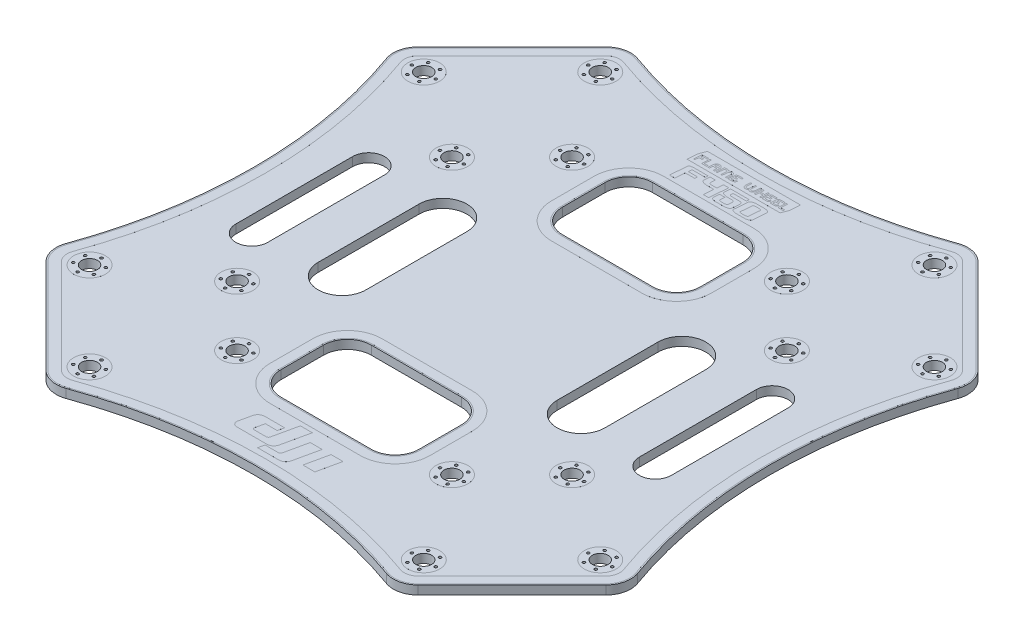
from build123d import *

# Parameters (mm, degrees)
BOSS_EXTRUDE1_DEPTH      = 0.825
BOSS_EXTRUDE1_DEPTH_BACK = 0.825
CUT_EXTRUDE1_DEPTH       = 1.65
SKETCH3_R                = 1.5
CUT_EXTRUDE2_DEPTH       = 1.65
SKETCH4_R                = 3
SKETCH4_R_2              = 1.5
SKETCH4_R_3              = 0.25
BOSS_EXTRUDE2_DEPTH      = 0.001
SKETCH5_R                = 0.25
CUT_EXTRUDE3_DEPTH       = 1.65
BOSS_EXTRUDE3_DEPTH      = 0.001


with BuildPart() as part:
    # Sketch1 → Boss-Extrude1 (new, two sides)
    with BuildSketch(Plane(origin=(0, 0, 0), x_dir=(1, 0, 0), z_dir=(0, 1, 0))) as boss_extrude1_sk:
        with BuildLine():
            Line((35.046361717, 52.705589829), (52.705589829, 35.046361717))
            ThreePointArc((52.705589829, 35.046361717), (53.961944938, 32.762265708), (53.8, 30.160478519))
            ThreePointArc((53.8, 30.160478519), (48.55, 0), (53.8, -30.160478519))
            ThreePointArc((53.8, -30.160478519), (53.961944938, -32.762265708), (52.705589829, -35.046361717))
            Line((52.705589829, -35.046361717), (35.046361717, -52.705589829))
            ThreePointArc((35.046361717, -52.705589829), (32.762265708, -53.961944938), (30.160478519, -53.8))
            ThreePointArc((30.160478519, -53.8), (0, -48.55), (-30.160478519, -53.8))
            ThreePointArc((-30.160478519, -53.8), (-32.762265708, -53.961944938), (-35.046361717, -52.705589829))
            Line((-35.046361717, -52.705589829), (-52.705589829, -35.046361717))
            ThreePointArc((-52.705589829, -35.046361717), (-53.961944938, -32.762265708), (-53.8, -30.160478519))
            ThreePointArc((-53.8, -30.160478519), (-48.55, 0), (-53.8, 30.160478519))
            ThreePointArc((-53.8, 30.160478519), (-53.961944938, 32.762265708), (-52.705589829, 35.046361717))
            Line((-52.705589829, 35.046361717), (-35.046361717, 52.705589829))
            ThreePointArc((-35.046361717, 52.705589829), (-32.762265708, 53.961944938), (-30.160478519, 53.8))
            ThreePointArc((-30.160478519, 53.8), (0, 48.55), (30.160478519, 53.8))
            ThreePointArc((30.160478519, 53.8), (32.762265708, 53.961944938), (35.046361717, 52.705589829))
        make_face()
    extrude(amount=BOSS_EXTRUDE1_DEPTH)
    extrude(boss_extrude1_sk.sketch, amount=-BOSS_EXTRUDE1_DEPTH_BACK)

    # Sketch2 → Cut-Extrude1 (cut)
    with BuildSketch(Plane(origin=(0, 0.825, 0), x_dir=(1, 0, 0), z_dir=(0, 1, 0))):
        with BuildLine():
            Line((13, 30.5), (13, 22.5))
            ThreePointArc((13, 22.5), (11.681980515, 19.318019485), (8.5, 18))
            Line((8.5, 18), (-8.5, 18))
            ThreePointArc((-8.5, 18), (-11.681980515, 19.318019485), (-13, 22.5))
            Line((-13, 22.5), (-13, 30.5))
            ThreePointArc((-13, 30.5), (-11.681980515, 33.681980515), (-8.5, 35))
            Line((-8.5, 35), (8.5, 35))
            ThreePointArc((8.5, 35), (11.681980515, 33.681980515), (13, 30.5))
        make_face()
        with BuildLine():
            Line((-13, -22.5), (-13, -30.5))
            ThreePointArc((-13, -30.5), (-11.681980515, -33.681980515), (-8.5, -35))
            Line((-8.5, -35), (8.5, -35))
            ThreePointArc((8.5, -35), (11.681980515, -33.681980515), (13, -30.5))
            Line((13, -30.5), (13, -22.5))
            ThreePointArc((13, -22.5), (11.681980515, -19.318019485), (8.5, -18))
            Line((8.5, -18), (-8.5, -18))
            ThreePointArc((-8.5, -18), (-11.681980515, -19.318019485), (-13, -22.5))
        make_face()
        with BuildLine():
            Line((-27, -9.5), (-27, 9.5))
            ThreePointArc((-27, 9.5), (-22.5, 14), (-18, 9.5))
            Line((-18, 9.5), (-18, -9.5))
            ThreePointArc((-18, -9.5), (-22.5, -14), (-27, -9.5))
        make_face()
        with BuildLine():
            Line((18, -9.5), (18, 9.5))
            ThreePointArc((18, 9.5), (22.5, 14), (27, 9.5))
            Line((27, 9.5), (27, -9.5))
            ThreePointArc((27, -9.5), (22.5, -14), (18, -9.5))
        make_face()
        with BuildLine():
            Line((-35, 11), (-35, -11))
            ThreePointArc((-35, -11), (-38, -14), (-41, -11))
            Line((-41, -11), (-41, 11))
            ThreePointArc((-41, 11), (-38, 14), (-35, 11))
        make_face()
        with BuildLine():
            Line((35, 11), (35, -11))
            ThreePointArc((35, -11), (38, -14), (41, -11))
            Line((41, -11), (41, 11))
            ThreePointArc((41, 11), (38, 14), (35, 11))
        make_face()
    extrude(amount=-CUT_EXTRUDE1_DEPTH, mode=Mode.SUBTRACT)

    # Sketch3 → Cut-Extrude2 (cut)
    with BuildSketch(Plane(origin=(0, 0.825, 0), x_dir=(1, 0, 0), z_dir=(0, 1, 0))):
        with Locations(Location((-48.083261121, -31.466251763, 0), (0, 0, 270))):
            Circle(SKETCH3_R)
        with Locations(Location((-31.466251763, -48.083261121, 0), (0, 0, 270))):
            Circle(SKETCH3_R)
        with Locations(Location((31.466251763, -48.083261121, 0), (0, 0, 270))):
            Circle(SKETCH3_R)
        with Locations(Location((48.083261121, -31.466251763, 0), (0, 0, 270))):
            Circle(SKETCH3_R)
        with Locations(Location((48.083261121, 31.466251763, 0), (0, 0, 270))):
            Circle(SKETCH3_R)
        with Locations(Location((31.466251763, 48.083261121, 0), (0, 0, 270))):
            Circle(SKETCH3_R)
        with Locations(Location((-31.466251763, 48.083261121, 0), (0, 0, 270))):
            Circle(SKETCH3_R)
        with Locations(Location((-48.083261121, 31.466251763, 0), (0, 0, 270))):
            Circle(SKETCH3_R)
        with Locations(Location((-31.540291459, -20.22658296, 0), (0, 0, 270))):
            Circle(SKETCH3_R)
        with Locations(Location((-20.22658296, -31.540291459, 0), (0, 0, 270))):
            Circle(SKETCH3_R)
        with Locations(Location((-31.540291459, 20.22658296, 0), (0, 0, 270))):
            Circle(SKETCH3_R)
        with Locations(Location((-20.22658296, 31.540291459, 0), (0, 0, 270))):
            Circle(SKETCH3_R)
        with Locations(Location((20.22658296, 31.540291459, 0), (0, 0, 270))):
            Circle(SKETCH3_R)
        with Locations(Location((31.540291459, 20.22658296, 0), (0, 0, 270))):
            Circle(SKETCH3_R)
        with Locations(Location((31.540291459, -20.22658296, 0), (0, 0, 270))):
            Circle(SKETCH3_R)
        with Locations(Location((20.22658296, -31.540291459, 0), (0, 0, 270))):
            Circle(SKETCH3_R)
    extrude(amount=-CUT_EXTRUDE2_DEPTH, mode=Mode.SUBTRACT)

    # Sketch4 → Boss-Extrude2 (add)
    with BuildSketch(Plane(origin=(0, 0.825, 0), x_dir=(1, 0, 0), z_dir=(0, 1, 0))):
        with BuildLine():
            Line((34.869585021, -52.528813133), (52.528813133, -34.869585021))
            ThreePointArc((52.528813133, -34.869585021), (53.71799007, -32.707621199), (53.564704439, -30.244953362))
            ThreePointArc((53.564704439, -30.244953362), (48.3, 0), (53.564704439, 30.244953362))
            ThreePointArc((53.564704439, 30.244953362), (53.71799007, 32.707621199), (52.528813133, 34.869585021))
            Line((52.528813133, 34.869585021), (34.869585021, 52.528813133))
            ThreePointArc((34.869585021, 52.528813133), (32.707621199, 53.71799007), (30.244953362, 53.564704439))
            ThreePointArc((30.244953362, 53.564704439), (0, 48.3), (-30.244953362, 53.564704439))
            ThreePointArc((-30.244953362, 53.564704439), (-32.707621199, 53.71799007), (-34.869585021, 52.528813133))
            Line((-34.869585021, 52.528813133), (-52.528813133, 34.869585021))
            ThreePointArc((-52.528813133, 34.869585021), (-53.71799007, 32.707621199), (-53.564704439, 30.244953362))
            ThreePointArc((-53.564704439, 30.244953362), (-48.3, 0), (-53.564704439, -30.244953362))
            ThreePointArc((-53.564704439, -30.244953362), (-53.71799007, -32.707621199), (-52.528813133, -34.869585021))
            Line((-52.528813133, -34.869585021), (-34.869585021, -52.528813133))
            ThreePointArc((-34.869585021, -52.528813133), (-32.707621199, -53.71799007), (-30.244953362, -53.564704439))
            ThreePointArc((-30.244953362, -53.564704439), (0, -48.3), (30.244953362, -53.564704439))
            ThreePointArc((30.244953362, -53.564704439), (32.707621199, -53.71799007), (34.869585021, -52.528813133))
        make_face()
        with BuildLine():
            Line((-51.256020927, 33.596792815), (-33.596792815, 51.256020927))
            ThreePointArc((-33.596792815, 51.256020927), (-32.314180733, 51.961515021), (-30.853172233, 51.870576403))
            ThreePointArc((-30.853172233, 51.870576403), (0, 46.5), (30.853172233, 51.870576403))
            ThreePointArc((30.853172233, 51.870576403), (32.314180733, 51.961515021), (33.596792815, 51.256020927))
            Line((33.596792815, 51.256020927), (51.256020927, 33.596792815))
            ThreePointArc((51.256020927, 33.596792815), (51.961515021, 32.314180733), (51.870576403, 30.853172233))
            ThreePointArc((51.870576403, 30.853172233), (46.5, 0), (51.870576403, -30.853172233))
            ThreePointArc((51.870576403, -30.853172233), (51.961515021, -32.314180733), (51.256020927, -33.596792815))
            Line((51.256020927, -33.596792815), (33.596792815, -51.256020927))
            ThreePointArc((33.596792815, -51.256020927), (32.314180733, -51.961515021), (30.853172233, -51.870576403))
            ThreePointArc((30.853172233, -51.870576403), (0, -46.5), (-30.853172233, -51.870576403))
            ThreePointArc((-30.853172233, -51.870576403), (-32.314180733, -51.961515021), (-33.596792815, -51.256020927))
            Line((-33.596792815, -51.256020927), (-51.256020927, -33.596792815))
            ThreePointArc((-51.256020927, -33.596792815), (-51.961515021, -32.314180733), (-51.870576403, -30.853172233))
            ThreePointArc((-51.870576403, -30.853172233), (-46.5, 0), (-51.870576403, 30.853172233))
            ThreePointArc((-51.870576403, 30.853172233), (-51.961515021, 32.314180733), (-51.256020927, 33.596792815))
        make_face(mode=Mode.SUBTRACT)
        with BuildLine():
            Line((15.05, 30.5), (15.05, 22.5))
            ThreePointArc((15.05, 22.5), (13.131549417, 17.868450583), (8.5, 15.95))
            Line((8.5, 15.95), (-8.5, 15.95))
            ThreePointArc((-8.5, 15.95), (-13.131549417, 17.868450583), (-15.05, 22.5))
            Line((-15.05, 22.5), (-15.05, 30.5))
            ThreePointArc((-15.05, 30.5), (-13.131549417, 35.131549417), (-8.5, 37.05))
            Line((-8.5, 37.05), (8.5, 37.05))
            ThreePointArc((8.5, 37.05), (13.131549417, 35.131549417), (15.05, 30.5))
        make_face()
        with BuildLine():
            Line((-8.5, 17.75), (8.5, 17.75))
            ThreePointArc((8.5, 17.75), (11.858757211, 19.141242789), (13.25, 22.5))
            Line((13.25, 22.5), (13.25, 30.5))
            ThreePointArc((13.25, 30.5), (11.858757211, 33.858757211), (8.5, 35.25))
            Line((8.5, 35.25), (-8.5, 35.25))
            ThreePointArc((-8.5, 35.25), (-11.858757211, 33.858757211), (-13.25, 30.5))
            Line((-13.25, 30.5), (-13.25, 22.5))
            ThreePointArc((-13.25, 22.5), (-11.858757211, 19.141242789), (-8.5, 17.75))
        make_face(mode=Mode.SUBTRACT)
        with BuildLine():
            Line((15.05, -30.5), (15.05, -22.5))
            ThreePointArc((15.05, -22.5), (13.131549417, -17.868450583), (8.5, -15.95))
            Line((8.5, -15.95), (-8.5, -15.95))
            ThreePointArc((-8.5, -15.95), (-13.131549417, -17.868450583), (-15.05, -22.5))
            Line((-15.05, -22.5), (-15.05, -30.5))
            ThreePointArc((-15.05, -30.5), (-13.131549417, -35.131549417), (-8.5, -37.05))
            Line((-8.5, -37.05), (8.5, -37.05))
            ThreePointArc((8.5, -37.05), (13.131549417, -35.131549417), (15.05, -30.5))
        make_face()
        with BuildLine():
            Line((13.25, -30.5), (13.25, -22.5))
            ThreePointArc((13.25, -22.5), (11.858757211, -19.141242789), (8.5, -17.75))
            Line((8.5, -17.75), (-8.5, -17.75))
            ThreePointArc((-8.5, -17.75), (-11.858757211, -19.141242789), (-13.25, -22.5))
            Line((-13.25, -22.5), (-13.25, -30.5))
            ThreePointArc((-13.25, -30.5), (-11.858757211, -33.858757211), (-8.5, -35.25))
            Line((-8.5, -35.25), (8.5, -35.25))
            ThreePointArc((8.5, -35.25), (11.858757211, -33.858757211), (13.25, -30.5))
        make_face(mode=Mode.SUBTRACT)
        with Locations(Location((31.466251763, -48.083261121, 0), (0, 0, 270))):
            Circle(SKETCH4_R)
        with Locations(Location((31.466251763, -48.083261121, 0), (0, 0, 270))):
            Circle(SKETCH4_R_2, mode=Mode.SUBTRACT)
        with Locations(Location((30.341251763, -50.031818279, 0), (0, 0, 270))):
            Circle(SKETCH4_R_3, mode=Mode.SUBTRACT)
        with Locations(Location((29.216251763, -48.083261121, 0), (0, 0, 270))):
            Circle(SKETCH4_R_3, mode=Mode.SUBTRACT)
        with Locations(Location((30.341251763, -46.134703962, 0), (0, 0, 270))):
            Circle(SKETCH4_R_3, mode=Mode.SUBTRACT)
        with Locations(Location((32.591251763, -46.134703962, 0), (0, 0, 270))):
            Circle(SKETCH4_R_3, mode=Mode.SUBTRACT)
        with Locations(Location((33.716251763, -48.083261121, 0), (0, 0, 270))):
            Circle(SKETCH4_R_3, mode=Mode.SUBTRACT)
        with Locations(Location((32.591251763, -50.031818279, 0), (0, 0, 270))):
            Circle(SKETCH4_R_3, mode=Mode.SUBTRACT)
        with Locations(Location((48.083261121, -31.466251763, 0), (0, 0, 270))):
            Circle(SKETCH4_R)
        with Locations(Location((48.083261121, -31.466251763, 0), (0, 0, 270))):
            Circle(SKETCH4_R_2, mode=Mode.SUBTRACT)
        with Locations(Location((46.958261121, -33.414808921, 0), (0, 0, 270))):
            Circle(SKETCH4_R_3, mode=Mode.SUBTRACT)
        with Locations(Location((45.833261121, -31.466251763, 0), (0, 0, 270))):
            Circle(SKETCH4_R_3, mode=Mode.SUBTRACT)
        with Locations(Location((46.958261121, -29.517694604, 0), (0, 0, 270))):
            Circle(SKETCH4_R_3, mode=Mode.SUBTRACT)
        with Locations(Location((49.208261121, -29.517694604, 0), (0, 0, 270))):
            Circle(SKETCH4_R_3, mode=Mode.SUBTRACT)
        with Locations(Location((50.333261121, -31.466251763, 0), (0, 0, 270))):
            Circle(SKETCH4_R_3, mode=Mode.SUBTRACT)
        with Locations(Location((49.208261121, -33.414808921, 0), (0, 0, 270))):
            Circle(SKETCH4_R_3, mode=Mode.SUBTRACT)
        with Locations(Location((31.540291459, -20.22658296, 0), (0, 0, 270))):
            Circle(SKETCH4_R)
        with Locations(Location((31.540291459, -20.22658296, 0), (0, 0, 270))):
            Circle(SKETCH4_R_2, mode=Mode.SUBTRACT)
        with Locations(Location((30.415291459, -22.175140119, 0), (0, 0, 270))):
            Circle(SKETCH4_R_3, mode=Mode.SUBTRACT)
        with Locations(Location((29.290291459, -20.22658296, 0), (0, 0, 270))):
            Circle(SKETCH4_R_3, mode=Mode.SUBTRACT)
        with Locations(Location((30.415291459, -18.278025802, 0), (0, 0, 270))):
            Circle(SKETCH4_R_3, mode=Mode.SUBTRACT)
        with Locations(Location((32.665291459, -18.278025802, 0), (0, 0, 270))):
            Circle(SKETCH4_R_3, mode=Mode.SUBTRACT)
        with Locations(Location((33.790291459, -20.22658296, 0), (0, 0, 270))):
            Circle(SKETCH4_R_3, mode=Mode.SUBTRACT)
        with Locations(Location((32.665291459, -22.175140119, 0), (0, 0, 270))):
            Circle(SKETCH4_R_3, mode=Mode.SUBTRACT)
        with Locations(Location((20.22658296, -31.540291459, 0), (0, 0, 270))):
            Circle(SKETCH4_R)
        with Locations(Location((20.22658296, -31.540291459, 0), (0, 0, 270))):
            Circle(SKETCH4_R_2, mode=Mode.SUBTRACT)
        with Locations(Location((19.10158296, -33.488848618, 0), (0, 0, 270))):
            Circle(SKETCH4_R_3, mode=Mode.SUBTRACT)
        with Locations(Location((21.35158296, -33.488848618, 0), (0, 0, 270))):
            Circle(SKETCH4_R_3, mode=Mode.SUBTRACT)
        with Locations(Location((22.47658296, -31.540291459, 0), (0, 0, 270))):
            Circle(SKETCH4_R_3, mode=Mode.SUBTRACT)
        with Locations(Location((21.35158296, -29.591734301, 0), (0, 0, 270))):
            Circle(SKETCH4_R_3, mode=Mode.SUBTRACT)
        with Locations(Location((19.10158296, -29.591734301, 0), (0, 0, 270))):
            Circle(SKETCH4_R_3, mode=Mode.SUBTRACT)
        with Locations(Location((17.97658296, -31.540291459, 0), (0, 0, 270))):
            Circle(SKETCH4_R_3, mode=Mode.SUBTRACT)
        with Locations(Location((31.540291459, 20.22658296, 0), (0, 0, 270))):
            Circle(SKETCH4_R)
        with Locations(Location((31.540291459, 20.22658296, 0), (0, 0, 270))):
            Circle(SKETCH4_R_2, mode=Mode.SUBTRACT)
        with Locations(Location((29.591734301, 21.35158296, 0), (0, 0, 270))):
            Circle(SKETCH4_R_3, mode=Mode.SUBTRACT)
        with Locations(Location((29.591734301, 19.10158296, 0), (0, 0, 270))):
            Circle(SKETCH4_R_3, mode=Mode.SUBTRACT)
        with Locations(Location((31.540291459, 17.97658296, 0), (0, 0, 270))):
            Circle(SKETCH4_R_3, mode=Mode.SUBTRACT)
        with Locations(Location((33.488848618, 19.10158296, 0), (0, 0, 270))):
            Circle(SKETCH4_R_3, mode=Mode.SUBTRACT)
        with Locations(Location((33.488848618, 21.35158296, 0), (0, 0, 270))):
            Circle(SKETCH4_R_3, mode=Mode.SUBTRACT)
        with Locations(Location((31.540291459, 22.47658296, 0), (0, 0, 270))):
            Circle(SKETCH4_R_3, mode=Mode.SUBTRACT)
        with Locations(Location((48.083261121, 31.466251763, 0), (0, 0, 270))):
            Circle(SKETCH4_R)
        with Locations(Location((48.083261121, 31.466251763, 0), (0, 0, 270))):
            Circle(SKETCH4_R_2, mode=Mode.SUBTRACT)
        with Locations(Location((48.083261121, 29.216251763, 0), (0, 0, 270))):
            Circle(SKETCH4_R_3, mode=Mode.SUBTRACT)
        with Locations(Location((46.134703962, 30.341251763, 0), (0, 0, 270))):
            Circle(SKETCH4_R_3, mode=Mode.SUBTRACT)
        with Locations(Location((50.031818279, 30.341251763, 0), (0, 0, 270))):
            Circle(SKETCH4_R_3, mode=Mode.SUBTRACT)
        with Locations(Location((50.031818279, 32.591251763, 0), (0, 0, 270))):
            Circle(SKETCH4_R_3, mode=Mode.SUBTRACT)
        with Locations(Location((48.083261121, 33.716251763, 0), (0, 0, 270))):
            Circle(SKETCH4_R_3, mode=Mode.SUBTRACT)
        with Locations(Location((46.134703962, 32.591251763, 0), (0, 0, 270))):
            Circle(SKETCH4_R_3, mode=Mode.SUBTRACT)
        with Locations(Location((31.466251763, 48.083261121, 0), (0, 0, 270))):
            Circle(SKETCH4_R)
        with Locations(Location((31.466251763, 48.083261121, 0), (0, 0, 270))):
            Circle(SKETCH4_R_2, mode=Mode.SUBTRACT)
        with Locations(Location((31.466251763, 45.833261121, 0), (0, 0, 270))):
            Circle(SKETCH4_R_3, mode=Mode.SUBTRACT)
        with Locations(Location((29.517694604, 46.958261121, 0), (0, 0, 270))):
            Circle(SKETCH4_R_3, mode=Mode.SUBTRACT)
        with Locations(Location((29.517694604, 49.208261121, 0), (0, 0, 270))):
            Circle(SKETCH4_R_3, mode=Mode.SUBTRACT)
        with Locations(Location((31.466251763, 50.333261121, 0), (0, 0, 270))):
            Circle(SKETCH4_R_3, mode=Mode.SUBTRACT)
        with Locations(Location((33.414808921, 49.208261121, 0), (0, 0, 270))):
            Circle(SKETCH4_R_3, mode=Mode.SUBTRACT)
        with Locations(Location((33.414808921, 46.958261121, 0), (0, 0, 270))):
            Circle(SKETCH4_R_3, mode=Mode.SUBTRACT)
        with Locations(Location((20.22658296, 31.540291459, 0), (0, 0, 270))):
            Circle(SKETCH4_R)
        with Locations(Location((20.22658296, 31.540291459, 0), (0, 0, 270))):
            Circle(SKETCH4_R_2, mode=Mode.SUBTRACT)
        with Locations(Location((20.22658296, 29.290291459, 0), (0, 0, 270))):
            Circle(SKETCH4_R_3, mode=Mode.SUBTRACT)
        with Locations(Location((22.175140119, 30.415291459, 0), (0, 0, 270))):
            Circle(SKETCH4_R_3, mode=Mode.SUBTRACT)
        with Locations(Location((22.175140119, 32.665291459, 0), (0, 0, 270))):
            Circle(SKETCH4_R_3, mode=Mode.SUBTRACT)
        with Locations(Location((18.278025802, 30.415291459, 0), (0, 0, 270))):
            Circle(SKETCH4_R_3, mode=Mode.SUBTRACT)
        with Locations(Location((18.278025802, 32.665291459, 0), (0, 0, 270))):
            Circle(SKETCH4_R_3, mode=Mode.SUBTRACT)
        with Locations(Location((20.22658296, 33.790291459, 0), (0, 0, 270))):
            Circle(SKETCH4_R_3, mode=Mode.SUBTRACT)
        with Locations(Location((-31.466251763, 48.083261121, 0), (0, 0, 270))):
            Circle(SKETCH4_R)
        with Locations(Location((-31.466251763, 48.083261121, 0), (0, 0, 270))):
            Circle(SKETCH4_R_2, mode=Mode.SUBTRACT)
        with Locations(Location((-32.591251763, 46.134703962, 0), (0, 0, 270))):
            Circle(SKETCH4_R_3, mode=Mode.SUBTRACT)
        with Locations(Location((-33.716251763, 48.083261121, 0), (0, 0, 270))):
            Circle(SKETCH4_R_3, mode=Mode.SUBTRACT)
        with Locations(Location((-32.591251763, 50.031818279, 0), (0, 0, 270))):
            Circle(SKETCH4_R_3, mode=Mode.SUBTRACT)
        with Locations(Location((-30.341251763, 50.031818279, 0), (0, 0, 270))):
            Circle(SKETCH4_R_3, mode=Mode.SUBTRACT)
        with Locations(Location((-29.216251763, 48.083261121, 0), (0, 0, 270))):
            Circle(SKETCH4_R_3, mode=Mode.SUBTRACT)
        with Locations(Location((-30.341251763, 46.134703962, 0), (0, 0, 270))):
            Circle(SKETCH4_R_3, mode=Mode.SUBTRACT)
        with Locations(Location((-20.22658296, 31.540291459, 0), (0, 0, 270))):
            Circle(SKETCH4_R)
        with Locations(Location((-20.22658296, 31.540291459, 0), (0, 0, 270))):
            Circle(SKETCH4_R_2, mode=Mode.SUBTRACT)
        with Locations(Location((-19.10158296, 29.591734301, 0), (0, 0, 270))):
            Circle(SKETCH4_R_3, mode=Mode.SUBTRACT)
        with Locations(Location((-21.35158296, 29.591734301, 0), (0, 0, 270))):
            Circle(SKETCH4_R_3, mode=Mode.SUBTRACT)
        with Locations(Location((-22.47658296, 31.540291459, 0), (0, 0, 270))):
            Circle(SKETCH4_R_3, mode=Mode.SUBTRACT)
        with Locations(Location((-21.35158296, 33.488848618, 0), (0, 0, 270))):
            Circle(SKETCH4_R_3, mode=Mode.SUBTRACT)
        with Locations(Location((-19.10158296, 33.488848618, 0), (0, 0, 270))):
            Circle(SKETCH4_R_3, mode=Mode.SUBTRACT)
        with Locations(Location((-17.97658296, 31.540291459, 0), (0, 0, 270))):
            Circle(SKETCH4_R_3, mode=Mode.SUBTRACT)
        with Locations(Location((-31.540291459, 20.22658296, 0), (0, 0, 270))):
            Circle(SKETCH4_R)
        with Locations(Location((-31.540291459, 20.22658296, 0), (0, 0, 270))):
            Circle(SKETCH4_R_2, mode=Mode.SUBTRACT)
        with Locations(Location((-32.665291459, 18.278025802, 0), (0, 0, 270))):
            Circle(SKETCH4_R_3, mode=Mode.SUBTRACT)
        with Locations(Location((-33.790291459, 20.22658296, 0), (0, 0, 270))):
            Circle(SKETCH4_R_3, mode=Mode.SUBTRACT)
        with Locations(Location((-32.665291459, 22.175140119, 0), (0, 0, 270))):
            Circle(SKETCH4_R_3, mode=Mode.SUBTRACT)
        with Locations(Location((-30.415291459, 22.175140119, 0), (0, 0, 270))):
            Circle(SKETCH4_R_3, mode=Mode.SUBTRACT)
        with Locations(Location((-29.290291459, 20.22658296, 0), (0, 0, 270))):
            Circle(SKETCH4_R_3, mode=Mode.SUBTRACT)
        with Locations(Location((-30.415291459, 18.278025802, 0), (0, 0, 270))):
            Circle(SKETCH4_R_3, mode=Mode.SUBTRACT)
        with Locations(Location((-48.083261121, 31.466251763, 0), (0, 0, 270))):
            Circle(SKETCH4_R)
        with Locations(Location((-48.083261121, 31.466251763, 0), (0, 0, 270))):
            Circle(SKETCH4_R_2, mode=Mode.SUBTRACT)
        with Locations(Location((-46.958261121, 29.517694604, 0), (0, 0, 270))):
            Circle(SKETCH4_R_3, mode=Mode.SUBTRACT)
        with Locations(Location((-45.833261121, 31.466251763, 0), (0, 0, 270))):
            Circle(SKETCH4_R_3, mode=Mode.SUBTRACT)
        with Locations(Location((-46.958261121, 33.414808921, 0), (0, 0, 270))):
            Circle(SKETCH4_R_3, mode=Mode.SUBTRACT)
        with Locations(Location((-49.208261121, 33.414808921, 0), (0, 0, 270))):
            Circle(SKETCH4_R_3, mode=Mode.SUBTRACT)
        with Locations(Location((-50.333261121, 31.466251763, 0), (0, 0, 270))):
            Circle(SKETCH4_R_3, mode=Mode.SUBTRACT)
        with Locations(Location((-49.208261121, 29.517694604, 0), (0, 0, 270))):
            Circle(SKETCH4_R_3, mode=Mode.SUBTRACT)
        with Locations(Location((-20.22658296, -31.540291459, 0), (0, 0, 270))):
            Circle(SKETCH4_R)
        with Locations(Location((-20.22658296, -31.540291459, 0), (0, 0, 270))):
            Circle(SKETCH4_R_2, mode=Mode.SUBTRACT)
        with Locations(Location((-20.22658296, -33.790291459, 0), (0, 0, 270))):
            Circle(SKETCH4_R_3, mode=Mode.SUBTRACT)
        with Locations(Location((-18.278025802, -32.665291459, 0), (0, 0, 270))):
            Circle(SKETCH4_R_3, mode=Mode.SUBTRACT)
        with Locations(Location((-18.278025802, -30.415291459, 0), (0, 0, 270))):
            Circle(SKETCH4_R_3, mode=Mode.SUBTRACT)
        with Locations(Location((-20.22658296, -29.290291459, 0), (0, 0, 270))):
            Circle(SKETCH4_R_3, mode=Mode.SUBTRACT)
        with Locations(Location((-22.175140119, -30.415291459, 0), (0, 0, 270))):
            Circle(SKETCH4_R_3, mode=Mode.SUBTRACT)
        with Locations(Location((-22.175140119, -32.665291459, 0), (0, 0, 270))):
            Circle(SKETCH4_R_3, mode=Mode.SUBTRACT)
        with Locations(Location((-31.540291459, -20.22658296, 0), (0, 0, 270))):
            Circle(SKETCH4_R)
        with Locations(Location((-31.540291459, -20.22658296, 0), (0, 0, 270))):
            Circle(SKETCH4_R_2, mode=Mode.SUBTRACT)
        with Locations(Location((-31.540291459, -22.47658296, 0), (0, 0, 270))):
            Circle(SKETCH4_R_3, mode=Mode.SUBTRACT)
        with Locations(Location((-29.591734301, -21.35158296, 0), (0, 0, 270))):
            Circle(SKETCH4_R_3, mode=Mode.SUBTRACT)
        with Locations(Location((-29.591734301, -19.10158296, 0), (0, 0, 270))):
            Circle(SKETCH4_R_3, mode=Mode.SUBTRACT)
        with Locations(Location((-31.540291459, -17.97658296, 0), (0, 0, 270))):
            Circle(SKETCH4_R_3, mode=Mode.SUBTRACT)
        with Locations(Location((-33.488848618, -19.10158296, 0), (0, 0, 270))):
            Circle(SKETCH4_R_3, mode=Mode.SUBTRACT)
        with Locations(Location((-33.488848618, -21.35158296, 0), (0, 0, 270))):
            Circle(SKETCH4_R_3, mode=Mode.SUBTRACT)
        with Locations(Location((-48.083261121, -31.466251763, 0), (0, 0, 270))):
            Circle(SKETCH4_R)
        with Locations(Location((-48.083261121, -31.466251763, 0), (0, 0, 270))):
            Circle(SKETCH4_R_2, mode=Mode.SUBTRACT)
        with Locations(Location((-48.083261121, -33.716251763, 0), (0, 0, 270))):
            Circle(SKETCH4_R_3, mode=Mode.SUBTRACT)
        with Locations(Location((-46.134703962, -32.591251763, 0), (0, 0, 270))):
            Circle(SKETCH4_R_3, mode=Mode.SUBTRACT)
        with Locations(Location((-46.134703962, -30.341251763, 0), (0, 0, 270))):
            Circle(SKETCH4_R_3, mode=Mode.SUBTRACT)
        with Locations(Location((-48.083261121, -29.216251763, 0), (0, 0, 270))):
            Circle(SKETCH4_R_3, mode=Mode.SUBTRACT)
        with Locations(Location((-50.031818279, -30.341251763, 0), (0, 0, 270))):
            Circle(SKETCH4_R_3, mode=Mode.SUBTRACT)
        with Locations(Location((-50.031818279, -32.591251763, 0), (0, 0, 270))):
            Circle(SKETCH4_R_3, mode=Mode.SUBTRACT)
        with Locations(Location((-31.466251763, -48.083261121, 0), (0, 0, 270))):
            Circle(SKETCH4_R)
        with Locations(Location((-31.466251763, -48.083261121, 0), (0, 0, 270))):
            Circle(SKETCH4_R_2, mode=Mode.SUBTRACT)
        with Locations(Location((-31.466251763, -50.333261121, 0), (0, 0, 270))):
            Circle(SKETCH4_R_3, mode=Mode.SUBTRACT)
        with Locations(Location((-29.517694604, -49.208261121, 0), (0, 0, 270))):
            Circle(SKETCH4_R_3, mode=Mode.SUBTRACT)
        with Locations(Location((-29.517694604, -46.958261121, 0), (0, 0, 270))):
            Circle(SKETCH4_R_3, mode=Mode.SUBTRACT)
        with Locations(Location((-31.466251763, -45.833261121, 0), (0, 0, 270))):
            Circle(SKETCH4_R_3, mode=Mode.SUBTRACT)
        with Locations(Location((-33.414808921, -46.958261121, 0), (0, 0, 270))):
            Circle(SKETCH4_R_3, mode=Mode.SUBTRACT)
        with Locations(Location((-33.414808921, -49.208261121, 0), (0, 0, 270))):
            Circle(SKETCH4_R_3, mode=Mode.SUBTRACT)
    boss_extrude2 = extrude(amount=BOSS_EXTRUDE2_DEPTH)

    # Mirror2: Boss-Extrude2 across plane
    add(boss_extrude2.mirror(Plane.ZX))

    # Sketch5 → Cut-Extrude3 (cut)
    with BuildSketch(Plane(origin=(0, 0.825, 0), x_dir=(1, 0, 0), z_dir=(0, 1, 0))):
        with Locations(Location((-31.466251763, -45.833261121, 0), (0, 0, 270))):
            Circle(SKETCH5_R)
        with Locations(Location((-29.517694604, -46.958261121, 0), (0, 0, 270))):
            Circle(SKETCH5_R)
        with Locations(Location((-29.517694604, -49.208261121, 0), (0, 0, 270))):
            Circle(SKETCH5_R)
        with Locations(Location((-31.466251763, -50.333261121, 0), (0, 0, 270))):
            Circle(SKETCH5_R)
        with Locations(Location((-33.414808921, -49.208261121, 0), (0, 0, 270))):
            Circle(SKETCH5_R)
        with Locations(Location((-33.414808921, -46.958261121, 0), (0, 0, 270))):
            Circle(SKETCH5_R)
        with Locations(Location((-48.083261121, -33.716251763, 0), (0, 0, 270))):
            Circle(SKETCH5_R)
        with Locations(Location((-50.031818279, -32.591251763, 0), (0, 0, 270))):
            Circle(SKETCH5_R)
        with Locations(Location((-50.031818279, -30.341251763, 0), (0, 0, 270))):
            Circle(SKETCH5_R)
        with Locations(Location((-48.083261121, -29.216251763, 0), (0, 0, 270))):
            Circle(SKETCH5_R)
        with Locations(Location((-46.134703962, -30.341251763, 0), (0, 0, 270))):
            Circle(SKETCH5_R)
        with Locations(Location((-46.134703962, -32.591251763, 0), (0, 0, 270))):
            Circle(SKETCH5_R)
        with Locations(Location((-33.488848618, -21.35158296, 0), (0, 0, 270))):
            Circle(SKETCH5_R)
        with Locations(Location((-33.488848618, -19.10158296, 0), (0, 0, 270))):
            Circle(SKETCH5_R)
        with Locations(Location((-31.540291459, -17.97658296, 0), (0, 0, 270))):
            Circle(SKETCH5_R)
        with Locations(Location((-29.591734301, -19.10158296, 0), (0, 0, 270))):
            Circle(SKETCH5_R)
        with Locations(Location((-29.591734301, -21.35158296, 0), (0, 0, 270))):
            Circle(SKETCH5_R)
        with Locations(Location((-31.540291459, -22.47658296, 0), (0, 0, 270))):
            Circle(SKETCH5_R)
        with Locations(Location((-22.175140119, -30.415291459, 0), (0, 0, 270))):
            Circle(SKETCH5_R)
        with Locations(Location((-22.175140119, -32.665291459, 0), (0, 0, 270))):
            Circle(SKETCH5_R)
        with Locations(Location((-20.22658296, -33.790291459, 0), (0, 0, 270))):
            Circle(SKETCH5_R)
        with Locations(Location((-18.278025802, -32.665291459, 0), (0, 0, 270))):
            Circle(SKETCH5_R)
        with Locations(Location((-18.278025802, -30.415291459, 0), (0, 0, 270))):
            Circle(SKETCH5_R)
        with Locations(Location((-20.22658296, -29.290291459, 0), (0, 0, 270))):
            Circle(SKETCH5_R)
        with Locations(Location((19.10158296, -33.488848618, 0), (0, 0, 270))):
            Circle(SKETCH5_R)
        with Locations(Location((17.97658296, -31.540291459, 0), (0, 0, 270))):
            Circle(SKETCH5_R)
        with Locations(Location((19.10158296, -29.591734301, 0), (0, 0, 270))):
            Circle(SKETCH5_R)
        with Locations(Location((21.35158296, -29.591734301, 0), (0, 0, 270))):
            Circle(SKETCH5_R)
        with Locations(Location((22.47658296, -31.540291459, 0), (0, 0, 270))):
            Circle(SKETCH5_R)
        with Locations(Location((21.35158296, -33.488848618, 0), (0, 0, 270))):
            Circle(SKETCH5_R)
        with Locations(Location((29.290291459, -20.22658296, 0), (0, 0, 270))):
            Circle(SKETCH5_R)
        with Locations(Location((30.415291459, -18.278025802, 0), (0, 0, 270))):
            Circle(SKETCH5_R)
        with Locations(Location((32.665291459, -18.278025802, 0), (0, 0, 270))):
            Circle(SKETCH5_R)
        with Locations(Location((30.415291459, -22.175140119, 0), (0, 0, 270))):
            Circle(SKETCH5_R)
        with Locations(Location((32.665291459, -22.175140119, 0), (0, 0, 270))):
            Circle(SKETCH5_R)
        with Locations(Location((33.790291459, -20.22658296, 0), (0, 0, 270))):
            Circle(SKETCH5_R)
        with Locations(Location((46.958261121, -29.517694604, 0), (0, 0, 270))):
            Circle(SKETCH5_R)
        with Locations(Location((49.208261121, -29.517694604, 0), (0, 0, 270))):
            Circle(SKETCH5_R)
        with Locations(Location((45.833261121, -31.466251763, 0), (0, 0, 270))):
            Circle(SKETCH5_R)
        with Locations(Location((46.958261121, -33.414808921, 0), (0, 0, 270))):
            Circle(SKETCH5_R)
        with Locations(Location((49.208261121, -33.414808921, 0), (0, 0, 270))):
            Circle(SKETCH5_R)
        with Locations(Location((50.333261121, -31.466251763, 0), (0, 0, 270))):
            Circle(SKETCH5_R)
        with Locations(Location((30.341251763, -46.134703962, 0), (0, 0, 270))):
            Circle(SKETCH5_R)
        with Locations(Location((32.591251763, -46.134703962, 0), (0, 0, 270))):
            Circle(SKETCH5_R)
        with Locations(Location((29.216251763, -48.083261121, 0), (0, 0, 270))):
            Circle(SKETCH5_R)
        with Locations(Location((30.341251763, -50.031818279, 0), (0, 0, 270))):
            Circle(SKETCH5_R)
        with Locations(Location((32.591251763, -50.031818279, 0), (0, 0, 270))):
            Circle(SKETCH5_R)
        with Locations(Location((33.716251763, -48.083261121, 0), (0, 0, 270))):
            Circle(SKETCH5_R)
        with Locations(Location((-32.665291459, 18.278025802, 0), (0, 0, 270))):
            Circle(SKETCH5_R)
        with Locations(Location((-33.790291459, 20.22658296, 0), (0, 0, 270))):
            Circle(SKETCH5_R)
        with Locations(Location((-32.665291459, 22.175140119, 0), (0, 0, 270))):
            Circle(SKETCH5_R)
        with Locations(Location((-30.415291459, 22.175140119, 0), (0, 0, 270))):
            Circle(SKETCH5_R)
        with Locations(Location((-29.290291459, 20.22658296, 0), (0, 0, 270))):
            Circle(SKETCH5_R)
        with Locations(Location((-30.415291459, 18.278025802, 0), (0, 0, 270))):
            Circle(SKETCH5_R)
        with Locations(Location((-49.208261121, 29.517694604, 0), (0, 0, 270))):
            Circle(SKETCH5_R)
        with Locations(Location((-50.333261121, 31.466251763, 0), (0, 0, 270))):
            Circle(SKETCH5_R)
        with Locations(Location((-49.208261121, 33.414808921, 0), (0, 0, 270))):
            Circle(SKETCH5_R)
        with Locations(Location((-46.958261121, 33.414808921, 0), (0, 0, 270))):
            Circle(SKETCH5_R)
        with Locations(Location((-45.833261121, 31.466251763, 0), (0, 0, 270))):
            Circle(SKETCH5_R)
        with Locations(Location((-46.958261121, 29.517694604, 0), (0, 0, 270))):
            Circle(SKETCH5_R)
        with Locations(Location((-32.591251763, 46.134703962, 0), (0, 0, 270))):
            Circle(SKETCH5_R)
        with Locations(Location((-33.716251763, 48.083261121, 0), (0, 0, 270))):
            Circle(SKETCH5_R)
        with Locations(Location((-32.591251763, 50.031818279, 0), (0, 0, 270))):
            Circle(SKETCH5_R)
        with Locations(Location((-30.341251763, 50.031818279, 0), (0, 0, 270))):
            Circle(SKETCH5_R)
        with Locations(Location((-29.216251763, 48.083261121, 0), (0, 0, 270))):
            Circle(SKETCH5_R)
        with Locations(Location((-30.341251763, 46.134703962, 0), (0, 0, 270))):
            Circle(SKETCH5_R)
        with Locations(Location((-21.35158296, 29.591734301, 0), (0, 0, 270))):
            Circle(SKETCH5_R)
        with Locations(Location((-22.47658296, 31.540291459, 0), (0, 0, 270))):
            Circle(SKETCH5_R)
        with Locations(Location((-21.35158296, 33.488848618, 0), (0, 0, 270))):
            Circle(SKETCH5_R)
        with Locations(Location((-19.10158296, 33.488848618, 0), (0, 0, 270))):
            Circle(SKETCH5_R)
        with Locations(Location((-17.97658296, 31.540291459, 0), (0, 0, 270))):
            Circle(SKETCH5_R)
        with Locations(Location((-19.10158296, 29.591734301, 0), (0, 0, 270))):
            Circle(SKETCH5_R)
        with Locations(Location((20.22658296, 29.290291459, 0), (0, 0, 270))):
            Circle(SKETCH5_R)
        with Locations(Location((18.278025802, 30.415291459, 0), (0, 0, 270))):
            Circle(SKETCH5_R)
        with Locations(Location((18.278025802, 32.665291459, 0), (0, 0, 270))):
            Circle(SKETCH5_R)
        with Locations(Location((20.22658296, 33.790291459, 0), (0, 0, 270))):
            Circle(SKETCH5_R)
        with Locations(Location((22.175140119, 32.665291459, 0), (0, 0, 270))):
            Circle(SKETCH5_R)
        with Locations(Location((22.175140119, 30.415291459, 0), (0, 0, 270))):
            Circle(SKETCH5_R)
        with Locations(Location((29.591734301, 21.35158296, 0), (0, 0, 270))):
            Circle(SKETCH5_R)
        with Locations(Location((31.540291459, 22.47658296, 0), (0, 0, 270))):
            Circle(SKETCH5_R)
        with Locations(Location((29.591734301, 19.10158296, 0), (0, 0, 270))):
            Circle(SKETCH5_R)
        with Locations(Location((31.540291459, 17.97658296, 0), (0, 0, 270))):
            Circle(SKETCH5_R)
        with Locations(Location((33.488848618, 19.10158296, 0), (0, 0, 270))):
            Circle(SKETCH5_R)
        with Locations(Location((33.488848618, 21.35158296, 0), (0, 0, 270))):
            Circle(SKETCH5_R)
        with Locations(Location((48.083261121, 29.216251763, 0), (0, 0, 270))):
            Circle(SKETCH5_R)
        with Locations(Location((50.031818279, 30.341251763, 0), (0, 0, 270))):
            Circle(SKETCH5_R)
        with Locations(Location((50.031818279, 32.591251763, 0), (0, 0, 270))):
            Circle(SKETCH5_R)
        with Locations(Location((48.083261121, 33.716251763, 0), (0, 0, 270))):
            Circle(SKETCH5_R)
        with Locations(Location((46.134703962, 32.591251763, 0), (0, 0, 270))):
            Circle(SKETCH5_R)
        with Locations(Location((46.134703962, 30.341251763, 0), (0, 0, 270))):
            Circle(SKETCH5_R)
        with Locations(Location((31.466251763, 45.833261121, 0), (0, 0, 270))):
            Circle(SKETCH5_R)
        with Locations(Location((29.517694604, 46.958261121, 0), (0, 0, 270))):
            Circle(SKETCH5_R)
        with Locations(Location((29.517694604, 49.208261121, 0), (0, 0, 270))):
            Circle(SKETCH5_R)
        with Locations(Location((31.466251763, 50.333261121, 0), (0, 0, 270))):
            Circle(SKETCH5_R)
        with Locations(Location((33.414808921, 49.208261121, 0), (0, 0, 270))):
            Circle(SKETCH5_R)
        with Locations(Location((33.414808921, 46.958261121, 0), (0, 0, 270))):
            Circle(SKETCH5_R)
    extrude(amount=-CUT_EXTRUDE3_DEPTH, mode=Mode.SUBTRACT)

    # Sketch6 → Boss-Extrude3 (add)
    with BuildSketch(Plane(origin=(0, 0.825, 0), x_dir=(1, 0, 0), z_dir=(0, 1, 0))):
        with BuildLine():
            Line((-3.447958462, -42.85), (-5.747958462, -42.85))
            ThreePointArc((-5.747958462, -42.85), (-5.967990585, -42.744609403), (-6.023783326, -42.507104702))
            Line((-6.023783326, -42.507104702), (-5.648783326, -40.797755411))
            Line((-5.648783326, -40.797755411), (-3.414519719, -40.797755411))
            Line((-3.414519719, -40.797755411), (-3.162230732, -39.647755411))
            Line((-3.162230732, -39.647755411), (-6.909692252, -39.647755411))
            ThreePointArc((-6.909692252, -39.647755411), (-7.724928026, -39.934950704), (-8.180145446, -40.669707536))
            Line((-8.180145446, -40.669707536), (-8.686553137, -42.978047874))
            ThreePointArc((-8.686553137, -42.978047874), (-8.520270572, -43.685897868), (-7.864495187, -44))
            Line((-7.864495187, -44), (-2.145453194, -44))
            ThreePointArc((-2.145453194, -44), (-1.330217421, -43.712804707), (-0.875, -42.978047874))
            Line((-0.875, -42.978047874), (0.25, -37.85))
            Line((0.25, -37.85), (-2, -37.85))
            Line((-2, -37.85), (-3.021683673, -42.507104702))
            ThreePointArc((-3.021683673, -42.507104702), (-3.174422642, -42.753637447), (-3.447958462, -42.85))
        make_face()
        with BuildLine():
            Line((3.897222752, -39.647755411), (1.647222752, -39.647755411))
            Line((1.647222752, -39.647755411), (0.703359065, -43.950136009))
            ThreePointArc((0.703359065, -43.950136009), (0.550620097, -44.196668754), (0.277084276, -44.293031307))
            Line((0.277084276, -44.293031307), (-2.209738909, -44.293031307))
            Line((-2.209738909, -44.293031307), (-2.462027895, -45.443031307))
            Line((-2.462027895, -45.443031307), (1.579589544, -45.443031307))
            ThreePointArc((1.579589544, -45.443031307), (2.394825318, -45.155836014), (2.850042739, -44.421079181))
            Line((2.850042739, -44.421079181), (3.897222752, -39.647755411))
        make_face()
        Polygon((7.827222752, -39.647755411), (5.577222752, -39.647755411), (4.622419817, -44), (6.872419817, -44), align=None)
        Polygon((-9.075, 42.05), (8.425, 42.05), (8.907868435, 43.256995474), (9.075, 45.25), (-8.425, 45.25), (-8.907868435, 44.043004526), align=None)
        with BuildLine():
            Line((-8.267020484, 42.71), (-8.517897987, 42.71))
            Line((-8.517897987, 42.71), (-8.412239746, 43.969949629))
            add(Edge.make_bspline(
                [(-7.886301335, 44.21), (-8.392109338, 44.21), (-8.412239746, 43.969949629)],
                knots=[1.570796327, 1.570796327, 1.570796327, 3.101783624, 3.101783624, 3.101783624], degree=2, weights=[1, 0.7210404, 1]))
            Line((-7.886301335, 44.21), (-7.162239746, 44.21))
            Line((-7.162239746, 44.21), (-7.18320452, 43.96))
            Line((-7.18320452, 43.96), (-7.886301335, 43.96))
            ThreePointArc((-7.886301335, 43.96), (-8.098433369, 43.872132034), (-8.186301335, 43.66))
            Line((-8.186301335, 43.66), (-7.616301335, 43.66))
            Line((-7.616301335, 43.66), (-7.637266109, 43.41))
            Line((-7.637266109, 43.41), (-8.208319114, 43.41))
            Line((-8.208319114, 43.41), (-8.267020484, 42.71))
        make_face(mode=Mode.SUBTRACT)
        with BuildLine():
            Line((-7.022999824, 42.889212169), (-6.912239746, 44.21))
            Line((-6.912239746, 44.21), (-6.662239746, 44.21))
            Line((-6.662239746, 44.21), (-6.759249383, 43.053182941))
            ThreePointArc((-6.759249383, 43.053182941), (-6.736852158, 42.987783999), (-6.673553606, 42.96))
            Line((-6.673553606, 42.96), (-6.013553606, 42.96))
            Line((-6.013553606, 42.96), (-6.034518381, 42.71))
            Line((-6.034518381, 42.71), (-6.858187188, 42.71))
            ThreePointArc((-6.858187188, 42.71), (-6.979924823, 42.763435003), (-7.022999824, 42.889212169))
        make_face(mode=Mode.SUBTRACT)
        with BuildLine():
            Line((-5.534518381, 42.71), (-5.784518381, 42.71))
            Line((-5.784518381, 42.71), (-5.706761824, 43.637228614))
            ThreePointArc((-5.706761824, 43.637228614), (-5.031719296, 44.207813914), (-4.461133995, 43.532771386))
            Line((-4.461133995, 43.532771386), (-4.530130863, 42.71))
            Line((-4.530130863, 42.71), (-4.780130863, 42.71))
            Line((-4.780130863, 42.71), (-4.727718926, 43.335))
            Line((-4.727718926, 43.335), (-5.482106444, 43.335))
            Line((-5.482106444, 43.335), (-5.534518381, 42.71))
        make_face(mode=Mode.SUBTRACT)
        with BuildLine():
            Line((-4.030130863, 42.71), (-4.280130863, 42.71))
            Line((-4.280130863, 42.71), (-4.154342214, 44.21))
            Line((-4.154342214, 44.21), (-3.637239618, 44.21))
            ThreePointArc((-3.637239618, 44.21), (-3.393530714, 44.154439768), (-3.197984611, 43.998739123))
            ThreePointArc((-3.197984611, 43.998739123), (-2.550723707, 44.170111095), (-2.198414925, 43.600731124))
            Line((-2.198414925, 43.600731124), (-2.273110835, 42.71))
            Line((-2.273110835, 42.71), (-2.523110835, 42.71))
            Line((-2.523110835, 42.71), (-2.446669115, 43.621549497))
            ThreePointArc((-2.446669115, 43.621549497), (-2.732560492, 43.959779098), (-3.070790092, 43.67388772))
            Line((-3.070790092, 43.67388772), (-3.151620849, 42.71))
            Line((-3.151620849, 42.71), (-3.401620849, 42.71))
            Line((-3.401620849, 42.71), (-3.325179129, 43.621549497))
            ThreePointArc((-3.325179129, 43.621549497), (-3.611070506, 43.959779098), (-3.949300107, 43.67388772))
            Line((-3.949300107, 43.67388772), (-4.030130863, 42.71))
        make_face(mode=Mode.SUBTRACT)
        with BuildLine():
            Line((-1.223110835, 42.71), (-2.023110835, 42.71))
            Line((-2.023110835, 42.71), (-1.917449524, 43.969986226))
            add(Edge.make_bspline(
                [(-1.39344469, 44.21), (-1.897322185, 44.21), (-1.917449524, 43.969986226)],
                knots=[4.71238898, 4.71238898, 4.71238898, 6.243229771, 6.243229771, 6.243229771], degree=2, weights=[1, 0.721091154, 1]))
            Line((-1.39344469, 44.21), (-0.667449524, 44.21))
            Line((-0.667449524, 44.21), (-0.688414299, 43.96))
            Line((-0.688414299, 43.96), (-1.39344469, 43.96))
            ThreePointArc((-1.39344469, 43.96), (-1.605576724, 43.872132034), (-1.69344469, 43.66))
            Line((-1.69344469, 43.66), (-1.12344469, 43.66))
            Line((-1.12344469, 43.66), (-1.144409465, 43.41))
            Line((-1.144409465, 43.41), (-1.714409465, 43.41))
            Line((-1.714409465, 43.41), (-1.75214606, 42.96))
            Line((-1.75214606, 42.96), (-1.20214606, 42.96))
            ThreePointArc((-1.20214606, 42.96), (-1.048399652, 43.023683847), (-0.984715805, 43.177430255))
            Line((-0.984715805, 43.177430255), (-0.75568058, 43.177430255))
            ThreePointArc((-0.75568058, 43.177430255), (-0.892587732, 42.846907152), (-1.223110835, 42.71))
        make_face(mode=Mode.SUBTRACT)
        with BuildLine():
            Line((2.518388675, 44.21), (2.768388675, 44.21))
            Line((2.768388675, 44.21), (2.685812109, 43.225293907))
            ThreePointArc((2.685812109, 43.225293907), (2.289121639, 42.734333921), (1.686242423, 42.921260877))
            ThreePointArc((1.686242423, 42.921260877), (1.038981519, 42.749888905), (0.686672737, 43.319268876))
            Line((0.686672737, 43.319268876), (0.761368647, 44.21))
            Line((0.761368647, 44.21), (1.011368647, 44.21))
            Line((1.011368647, 44.21), (0.934926927, 43.298450503))
            ThreePointArc((0.934926927, 43.298450503), (1.220818304, 42.960220902), (1.559047905, 43.24611228))
            Line((1.559047905, 43.24611228), (1.639878661, 44.21))
            Line((1.639878661, 44.21), (1.889878661, 44.21))
            Line((1.889878661, 44.21), (1.813436941, 43.298450503))
            ThreePointArc((1.813436941, 43.298450503), (2.099328318, 42.960220902), (2.437557919, 43.24611228))
            Line((2.437557919, 43.24611228), (2.518388675, 44.21))
        make_face(mode=Mode.SUBTRACT)
        Polygon((4.022776193, 44.21), (4.272776193, 44.21), (4.146987543, 42.71), (3.896987543, 42.71), (3.949436145, 43.335437217), (3.195048628, 43.335437217), (3.142600026, 42.71), (2.892600026, 42.71), (3.018388675, 44.21), (3.268388675, 44.21), (3.215940073, 43.584562783), (3.970327591, 43.584562783), align=None, mode=Mode.SUBTRACT)
        with BuildLine():
            Line((5.026653688, 44.21), (5.752648854, 44.21))
            Line((5.752648854, 44.21), (5.731684079, 43.96))
            Line((5.731684079, 43.96), (5.026653688, 43.96))
            ThreePointArc((5.026653688, 43.96), (4.814521654, 43.872132034), (4.726653688, 43.66))
            Line((4.726653688, 43.66), (5.296653688, 43.66))
            Line((5.296653688, 43.66), (5.275688913, 43.41))
            Line((5.275688913, 43.41), (4.705688913, 43.41))
            Line((4.705688913, 43.41), (4.667952318, 42.96))
            Line((4.667952318, 42.96), (5.217952318, 42.96))
            ThreePointArc((5.217952318, 42.96), (5.371698726, 43.023683847), (5.435382573, 43.177430255))
            Line((5.435382573, 43.177430255), (5.664417798, 43.177430255))
            ThreePointArc((5.664417798, 43.177430255), (5.527510646, 42.846907152), (5.196987543, 42.71))
            Line((5.196987543, 42.71), (4.396987543, 42.71))
            Line((4.396987543, 42.71), (4.502648854, 43.969986226))
            add(Edge.make_bspline(
                [(5.026653688, 44.21), (4.522776193, 44.21), (4.502648854, 43.969986226)],
                knots=[1.570796327, 1.570796327, 1.570796327, 3.101637118, 3.101637118, 3.101637118], degree=2, weights=[1, 0.721091154, 1]))
        make_face(mode=Mode.SUBTRACT)
        with BuildLine():
            Line((6.676860204, 42.71), (5.876860204, 42.71))
            Line((5.876860204, 42.71), (5.982521515, 43.969986226))
            add(Edge.make_bspline(
                [(6.506526349, 44.21), (6.002648854, 44.21), (5.982521515, 43.969986226)],
                knots=[1.570796327, 1.570796327, 1.570796327, 3.101637118, 3.101637118, 3.101637118], degree=2, weights=[1, 0.721091154, 1]))
            Line((6.506526349, 44.21), (7.232521515, 44.21))
            Line((7.232521515, 44.21), (7.21155674, 43.96))
            Line((7.21155674, 43.96), (6.506526349, 43.96))
            ThreePointArc((6.506526349, 43.96), (6.294394315, 43.872132034), (6.206526349, 43.66))
            Line((6.206526349, 43.66), (6.776526349, 43.66))
            Line((6.776526349, 43.66), (6.755561574, 43.41))
            Line((6.755561574, 43.41), (6.185561574, 43.41))
            Line((6.185561574, 43.41), (6.147824979, 42.96))
            Line((6.147824979, 42.96), (6.697824979, 42.96))
            ThreePointArc((6.697824979, 42.96), (6.851571387, 43.023683847), (6.915255234, 43.177430255))
            Line((6.915255234, 43.177430255), (7.144290459, 43.177430255))
            ThreePointArc((7.144290459, 43.177430255), (7.007383307, 42.846907152), (6.676860204, 42.71))
        make_face(mode=Mode.SUBTRACT)
        with BuildLine():
            Line((8.381207655, 42.96), (8.36024288, 42.71))
            Line((8.36024288, 42.71), (7.536574072, 42.71))
            ThreePointArc((7.536574072, 42.71), (7.414836438, 42.763435003), (7.371761437, 42.889212169))
            Line((7.371761437, 42.889212169), (7.482521515, 44.21))
            Line((7.482521515, 44.21), (7.732521515, 44.21))
            Line((7.732521515, 44.21), (7.635511878, 43.053182941))
            ThreePointArc((7.635511878, 43.053182941), (7.657909103, 42.987783999), (7.721207655, 42.96))
            Line((7.721207655, 42.96), (8.381207655, 42.96))
        make_face(mode=Mode.SUBTRACT)
        with BuildLine():
            Line((-5.461141669, 43.585), (-4.708073475, 43.585))
            ThreePointArc((-4.708073475, 43.585), (-5.068229038, 43.960545613), (-5.458507634, 43.616410241))
            Line((-5.458507634, 43.616410241), (-5.461141669, 43.585))
        make_face()
        with BuildLine():
            Line((-7.878411206, 41.038632354), (-8.15, 37.8))
            Line((-8.15, 37.8), (-7.15, 37.8))
            Line((-7.15, 37.8), (-6.995699257, 39.64))
            Line((-6.995699257, 39.64), (-5.236046717, 39.64))
            Line((-5.236046717, 39.64), (-5.194117168, 40.14))
            Line((-5.194117168, 40.14), (-6.953769707, 40.14))
            Line((-6.953769707, 40.14), (-6.898422701, 40.8))
            Line((-6.898422701, 40.8), (-4.386137651, 40.8))
            Line((-4.386137651, 40.8), (-4.344208101, 41.3))
            Line((-4.344208101, 41.3), (-6.856493151, 41.3))
            add(Edge.make_bspline(
                [(-6.856493151, 41.3), (-7.856493151, 41.3), (-7.878411206, 41.038632354)],
                knots=[4.688869079, 4.688869079, 4.688869079, 6.259665405, 6.259665405, 6.259665405], degree=2, weights=[1, 0.707106781, 1]))
        make_face()
        with BuildLine():
            Line((-2.994208101, 41.3), (-3.994208101, 41.3))
            Line((-3.994208101, 41.3), (-4.091484657, 40.14))
            add(Edge.make_bspline(
                [(-4.091484657, 40.14), (-4.133414207, 39.64), (-2.76934259, 39.64)],
                knots=[3.106104028, 3.106104028, 3.106104028, 4.676900354, 4.676900354, 4.676900354], degree=2, weights=[1, 0.707106781, 1]))
            Line((-2.76934259, 39.64), (-1.621129157, 39.64))
            Line((-1.621129157, 39.64), (-1.775429901, 37.8))
            Line((-1.775429901, 37.8), (-0.775429901, 37.8))
            Line((-0.775429901, 37.8), (-0.481923052, 41.3))
            Line((-0.481923052, 41.3), (-1.481923052, 41.3))
            Line((-1.481923052, 41.3), (-1.579199607, 40.14))
            Line((-1.579199607, 40.14), (-2.727413041, 40.14))
            ThreePointArc((-2.727413041, 40.14), (-2.973859437, 40.248174141), (-3.061060727, 40.50279819))
            Line((-3.061060727, 40.50279819), (-2.994208101, 41.3))
        make_face()
        with BuildLine():
            Line((3.380361998, 41.3), (-0.131923052, 41.3))
            Line((-0.131923052, 41.3), (-0.229199607, 40.14))
            add(Edge.make_bspline(
                [(-0.229199607, 40.14), (-0.271129157, 39.64), (1.092942459, 39.64)],
                knots=[3.106104028, 3.106104028, 3.106104028, 4.676900354, 4.676900354, 4.676900354], degree=2, weights=[1, 0.707106781, 1]))
            Line((1.092942459, 39.64), (1.877084276, 39.64))
            ThreePointArc((1.877084276, 39.64), (2.123530673, 39.531825859), (2.210731963, 39.27720181))
            Line((2.210731963, 39.27720181), (2.144073337, 38.482313407))
            add(Edge.make_bspline(
                [(0.632432878, 38.49), (0.616825272, 38.303882974), (1.372645501, 38.300039678), (2.128465731, 38.296196381), (2.144073337, 38.482313407)],
                knots=[3.120945696, 3.120945696, 3.120945696, 4.691742023, 4.691742023, 6.262538349, 6.262538349, 6.262538349], degree=2, weights=[1, 0.707106781, 1, 0.707106781, 1]))
            Line((0.632432878, 38.49), (0.707906068, 39.39))
            Line((0.707906068, 39.39), (-0.292093932, 39.39))
            Line((-0.292093932, 39.39), (-0.383500351, 38.3))
            add(Edge.make_bspline(
                [(-0.383500351, 38.3), (-0.425429901, 37.8), (0.574570099, 37.8)],
                knots=[6.227380754, 6.227380754, 6.227380754, 7.798177081, 7.798177081, 7.798177081], degree=2, weights=[1, 0.707106781, 1]))
            Line((0.574570099, 37.8), (2.086855149, 37.8))
            add(Edge.make_bspline(
                [(2.086855149, 37.8), (3.086855149, 37.8), (3.128784699, 38.3)],
                knots=[4.656584428, 4.656584428, 4.656584428, 6.227380754, 6.227380754, 6.227380754], degree=2, weights=[1, 0.707106781, 1]))
            Line((3.128784699, 38.3), (3.241155893, 39.64))
            ThreePointArc((3.241155893, 39.64), (3.120977109, 39.990916923), (2.781330435, 40.14))
            Line((2.781330435, 40.14), (1.134872009, 40.14))
            ThreePointArc((1.134872009, 40.14), (0.888425613, 40.248174141), (0.801224322, 40.50279819))
            Line((0.801224322, 40.50279819), (0.826147399, 40.8))
            Line((0.826147399, 40.8), (3.338432448, 40.8))
            Line((3.338432448, 40.8), (3.380361998, 41.3))
        make_face()
        with BuildLine():
            add(Edge.make_bspline(
                [(4.730361998, 41.3), (3.730361998, 41.3), (3.688432448, 40.8)],
                knots=[4.656584428, 4.656584428, 4.656584428, 6.227380754, 6.227380754, 6.227380754], degree=2, weights=[1, 0.707106781, 1]))
            Line((3.688432448, 40.8), (3.478784699, 38.3))
            add(Edge.make_bspline(
                [(3.478784699, 38.3), (3.436855149, 37.8), (4.436855149, 37.8)],
                knots=[3.085788101, 3.085788101, 3.085788101, 4.656584428, 4.656584428, 4.656584428], degree=2, weights=[1, 0.707106781, 1]))
            Line((4.436855149, 37.8), (5.949140199, 37.8))
            add(Edge.make_bspline(
                [(5.949140199, 37.8), (6.949140199, 37.8), (6.991069749, 38.3)],
                knots=[4.656584428, 4.656584428, 4.656584428, 6.227380754, 6.227380754, 6.227380754], degree=2, weights=[1, 0.707106781, 1]))
            Line((6.991069749, 38.3), (7.200717498, 40.8))
            add(Edge.make_bspline(
                [(7.200717498, 40.8), (7.242647048, 41.3), (6.242647048, 41.3)],
                knots=[6.227380754, 6.227380754, 6.227380754, 7.798177081, 7.798177081, 7.798177081], degree=2, weights=[1, 0.707106781, 1]))
            Line((6.242647048, 41.3), (4.730361998, 41.3))
        make_face()
        with BuildLine():
            add(Edge.make_bspline(
                [(4.494717928, 38.49), (4.478784699, 38.3), (5.234927224, 38.3), (5.991069749, 38.3), (6.007002978, 38.49)],
                knots=[6.260697969, 6.260697969, 6.260697969, 7.831494296, 7.831494296, 9.402290623, 9.402290623, 9.402290623], degree=2, weights=[1, 0.707106781, 1, 0.707106781, 1]))
            Line((4.494717928, 38.49), (4.672499219, 40.61))
            add(Edge.make_bspline(
                [(6.184784269, 40.61), (6.20072153, 40.800048077), (5.444579005, 40.800048077), (4.68843648, 40.800048077), (4.672499219, 40.61)],
                knots=[6.260691515, 6.260691515, 6.260691515, 7.831487842, 7.831487842, 9.402284169, 9.402284169, 9.402284169], degree=2, weights=[1, 0.707106781, 1, 0.707106781, 1]))
            Line((6.184784269, 40.61), (6.007002978, 38.49))
        make_face(mode=Mode.SUBTRACT)
    extrude(amount=BOSS_EXTRUDE3_DEPTH)


solid = part.part
